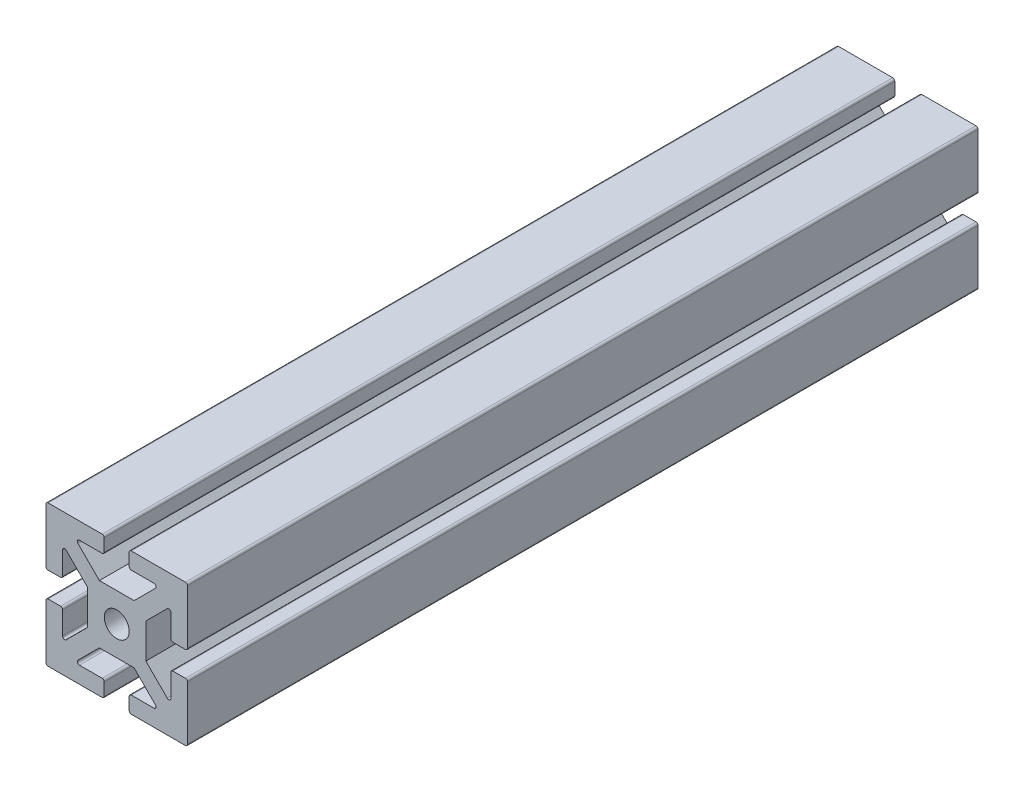
from build123d import *

# Parameters (mm, degrees)
SKETCH1_R           = 1.5
BOSS_EXTRUDE1_DEPTH = 95


with BuildPart() as part:
    # Sketch1 → Boss-Extrude1 (new body)
    with BuildSketch(Plane.XY):
        with BuildLine():
            Line((-2.085786438, 3.5), (2.085786438, 3.5))
            Line((2.085786438, 3.5), (4.659009742, 6.073223305))
            ThreePointArc((4.659009742, 6.073223305), (4.71320293, 6.345670858), (4.482233047, 6.5))
            Line((4.482233047, 6.5), (1.75, 6.5))
            ThreePointArc((1.75, 6.5), (1.573223305, 6.573223305), (1.5, 6.75))
            Line((1.5, 6.75), (1.5, 8.25))
            ThreePointArc((1.5, 8.25), (1.573223305, 8.426776695), (1.75, 8.5))
            Line((1.75, 8.5), (8.25, 8.5))
            ThreePointArc((8.25, 8.5), (8.426776695, 8.426776695), (8.5, 8.25))
            Line((8.5, 8.25), (8.5, 1.75))
            ThreePointArc((8.5, 1.75), (8.426776695, 1.573223305), (8.25, 1.5))
            Line((8.25, 1.5), (6.75, 1.5))
            ThreePointArc((6.75, 1.5), (6.573223305, 1.573223305), (6.5, 1.75))
            Line((6.5, 1.75), (6.5, 4.482233047))
            ThreePointArc((6.5, 4.482233047), (6.345670858, 4.71320293), (6.073223305, 4.659009742))
            Line((6.073223305, 4.659009742), (3.5, 2.085786438))
            Line((3.5, 2.085786438), (3.5, -2.085786438))
            Line((3.5, -2.085786438), (6.073223305, -4.659009742))
            ThreePointArc((6.073223305, -4.659009742), (6.345670858, -4.71320293), (6.5, -4.482233047))
            Line((6.5, -4.482233047), (6.5, -1.75))
            ThreePointArc((6.5, -1.75), (6.573223305, -1.573223305), (6.75, -1.5))
            Line((6.75, -1.5), (8.25, -1.5))
            ThreePointArc((8.25, -1.5), (8.426776695, -1.573223305), (8.5, -1.75))
            Line((8.5, -1.75), (8.5, -8.25))
            ThreePointArc((8.5, -8.25), (8.426776695, -8.426776695), (8.25, -8.5))
            Line((8.25, -8.5), (1.75, -8.5))
            ThreePointArc((1.75, -8.5), (1.573223305, -8.426776695), (1.5, -8.25))
            Line((1.5, -8.25), (1.5, -6.75))
            ThreePointArc((1.5, -6.75), (1.573223305, -6.573223305), (1.75, -6.5))
            Line((1.75, -6.5), (4.482233047, -6.5))
            ThreePointArc((4.482233047, -6.5), (4.71320293, -6.345670858), (4.659009742, -6.073223305))
            Line((4.659009742, -6.073223305), (2.085786438, -3.5))
            Line((2.085786438, -3.5), (-2.085786438, -3.5))
            Line((-2.085786438, -3.5), (-4.659009742, -6.073223305))
            ThreePointArc((-4.659009742, -6.073223305), (-4.71320293, -6.345670858), (-4.482233047, -6.5))
            Line((-4.482233047, -6.5), (-1.75, -6.5))
            ThreePointArc((-1.75, -6.5), (-1.573223305, -6.573223305), (-1.5, -6.75))
            Line((-1.5, -6.75), (-1.5, -8.25))
            ThreePointArc((-1.5, -8.25), (-1.573223305, -8.426776695), (-1.75, -8.5))
            Line((-1.75, -8.5), (-8.25, -8.5))
            ThreePointArc((-8.25, -8.5), (-8.426776695, -8.426776695), (-8.5, -8.25))
            Line((-8.5, -8.25), (-8.5, -1.75))
            ThreePointArc((-8.5, -1.75), (-8.426776695, -1.573223305), (-8.25, -1.5))
            Line((-8.25, -1.5), (-6.75, -1.5))
            ThreePointArc((-6.75, -1.5), (-6.573223305, -1.573223305), (-6.5, -1.75))
            Line((-6.5, -1.75), (-6.5, -4.482233047))
            ThreePointArc((-6.5, -4.482233047), (-6.345670858, -4.71320293), (-6.073223305, -4.659009742))
            Line((-6.073223305, -4.659009742), (-3.5, -2.085786438))
            Line((-3.5, -2.085786438), (-3.5, 2.085786438))
            Line((-3.5, 2.085786438), (-6.073223305, 4.659009742))
            ThreePointArc((-6.073223305, 4.659009742), (-6.345670858, 4.71320293), (-6.5, 4.482233047))
            Line((-6.5, 4.482233047), (-6.5, 1.75))
            ThreePointArc((-6.5, 1.75), (-6.573223305, 1.573223305), (-6.75, 1.5))
            Line((-6.75, 1.5), (-8.25, 1.5))
            ThreePointArc((-8.25, 1.5), (-8.426776695, 1.573223305), (-8.5, 1.75))
            Line((-8.5, 1.75), (-8.5, 8.25))
            ThreePointArc((-8.5, 8.25), (-8.426776695, 8.426776695), (-8.25, 8.5))
            Line((-8.25, 8.5), (-1.75, 8.5))
            ThreePointArc((-1.75, 8.5), (-1.573223305, 8.426776695), (-1.5, 8.25))
            Line((-1.5, 8.25), (-1.5, 6.75))
            ThreePointArc((-1.5, 6.75), (-1.573223305, 6.573223305), (-1.75, 6.5))
            Line((-1.75, 6.5), (-4.482233047, 6.5))
            ThreePointArc((-4.482233047, 6.5), (-4.71320293, 6.345670858), (-4.659009742, 6.073223305))
            Line((-4.659009742, 6.073223305), (-2.085786438, 3.5))
        make_face()
        Circle(SKETCH1_R, mode=Mode.SUBTRACT)
    extrude(amount=BOSS_EXTRUDE1_DEPTH)


solid = part.part
